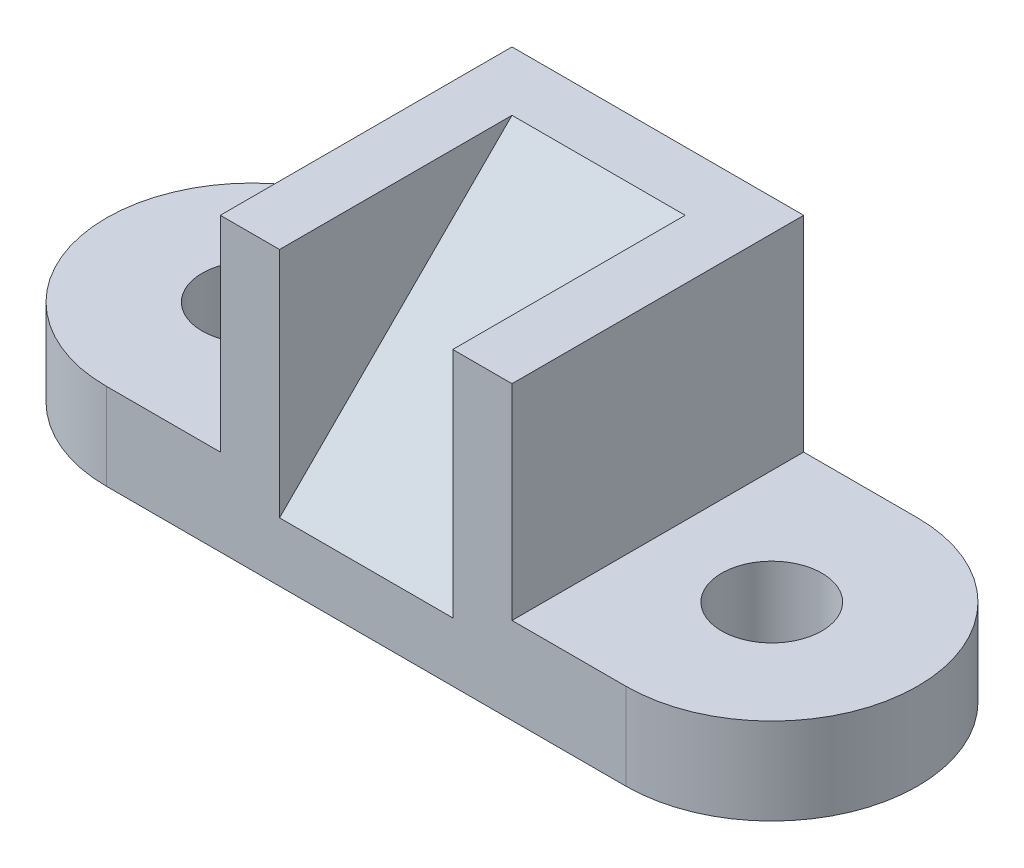
from build123d import *

# Parameters (mm, degrees)
SKETCH1_R           = 11
BOSS_EXTRUDE1_DEPTH = 19
BOSS_EXTRUDE2_DEPTH = 45
SKETCH7_W           = 38
SKETCH7_H           = 6
CUT_EXTRUDE8_DEPTH  = 51
BOSS_EXTRUDE3_DEPTH = 51


with BuildPart() as part:
    # Sketch1 → Boss-Extrude1 (new body)
    with BuildSketch(Plane(origin=(0, 0, 0), x_dir=(1, 0, 0), z_dir=(0, 1, 0))):
        with BuildLine():
            Line((0, 0), (114, 0))
            ThreePointArc((114, 0), (146, -32), (114, -64))
            Line((114, -64), (0, -64))
            ThreePointArc((0, -64), (-32, -32), (0, 0))
        make_face()
        with Locations((0, -32)):
            Circle(SKETCH1_R, mode=Mode.SUBTRACT)
        with Locations((114, -32)):
            Circle(SKETCH1_R, mode=Mode.SUBTRACT)
    extrude(amount=BOSS_EXTRUDE1_DEPTH)

    # Sketch3 → Boss-Extrude2 (add)
    with BuildSketch(Plane(origin=(0, 19, 0), x_dir=(1, 0, 0), z_dir=(0, 1, 0))):
        Polygon((25, 0), (25, -64), (38, -64), (38, -13), (76, -13), (76, -64), (89, -64), (89, 0), align=None)
    extrude(amount=BOSS_EXTRUDE2_DEPTH)

    # Sketch7 → Cut-Extrude8 (cut)
    with BuildSketch(Plane.XY.offset(64)):
        with Locations((57, 16)):
            Rectangle(SKETCH7_W, SKETCH7_H)
    extrude(amount=-CUT_EXTRUDE8_DEPTH, mode=Mode.SUBTRACT)

    # Sketch8 → Boss-Extrude3 (add)
    with BuildSketch(Plane(origin=(38, 0, 0), x_dir=(0, 0, -1), z_dir=(1, 0, 0))):
        Polygon((-13, 64), (-64, 13), (-13, 13), align=None)
    extrude(amount=BOSS_EXTRUDE3_DEPTH)


solid = part.part
